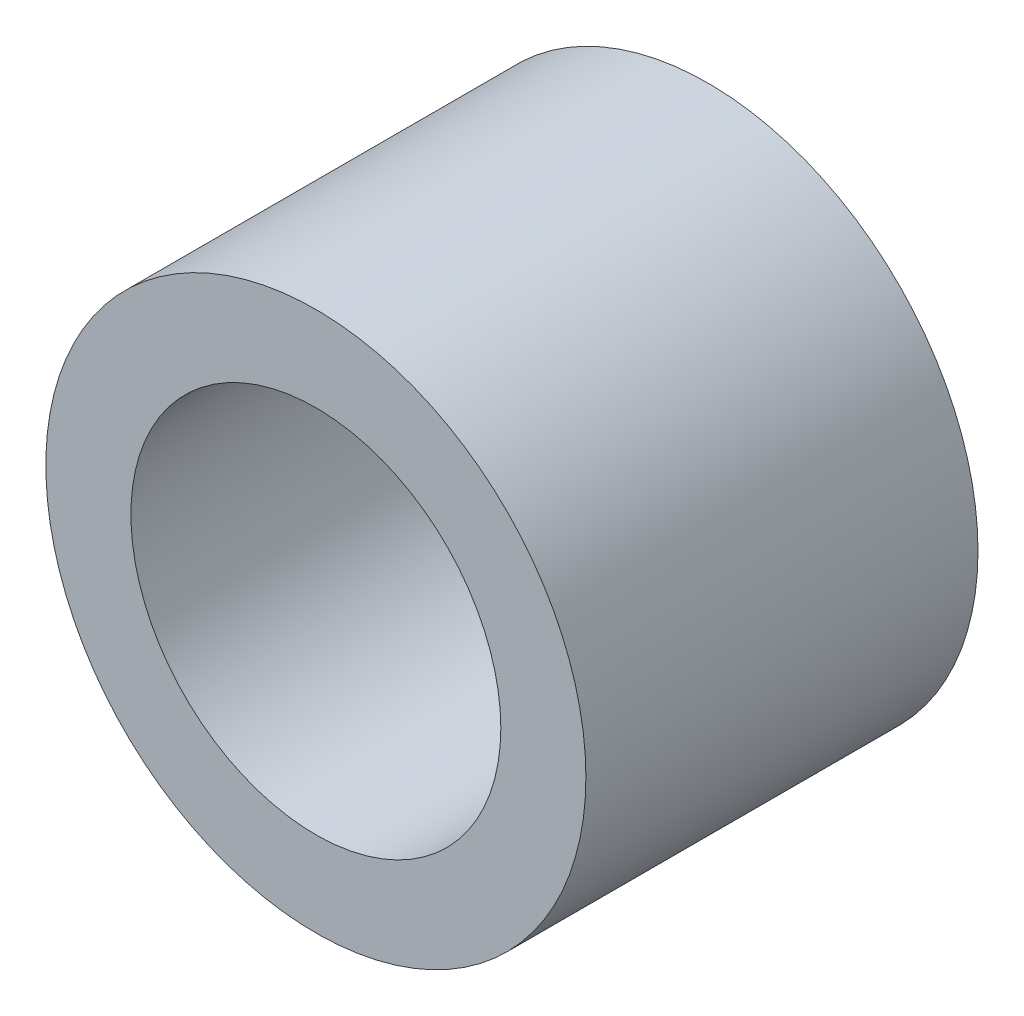
from build123d import *

# Parameters (mm, degrees)
SKIZZE1_R                       = 3.65
SKIZZE1_R_2                     = 2.5
AUFSATZ_LINEAR_AUSTRAGEN1_DEPTH = 5.3


with BuildPart() as part:
    # Skizze1 → Aufsatz-Linear austragen1 (new body)
    with BuildSketch(Plane.XY):
        Circle(SKIZZE1_R)
        Circle(SKIZZE1_R_2, mode=Mode.SUBTRACT)
    extrude(amount=AUFSATZ_LINEAR_AUSTRAGEN1_DEPTH)


solid = part.part
